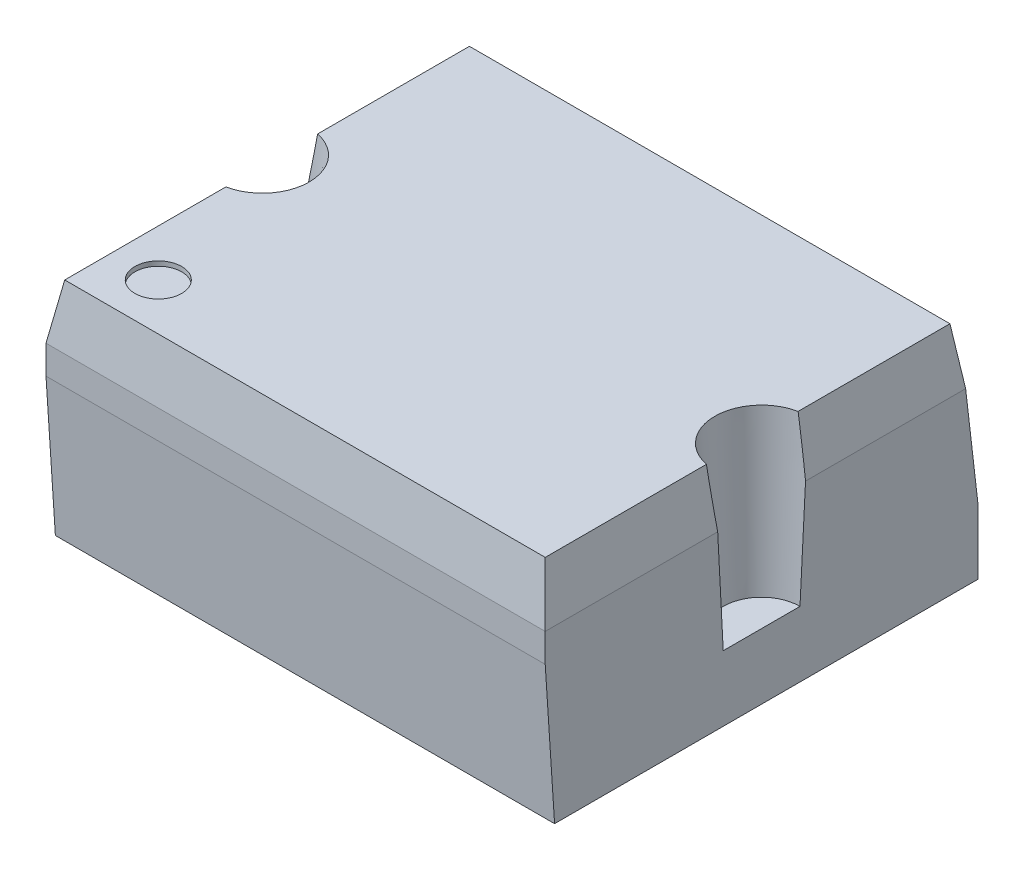
from build123d import *

# Parameters (mm, degrees)
SKETCH1_W           = 10.67
SKETCH1_H           = 9.25
BOSS_EXTRUDE1_DEPTH = 4.83
CUT_EXTRUDE1_DEPTH  = 11.67
CUT_EXTRUDE2_DEPTH  = 10.25
CUT_EXTRUDE3_DEPTH  = 11.67
CUT_EXTRUDE4_DEPTH  = 11.67
SKETCH7_R           = 1
CUT_EXTRUDE5_DEPTH  = 3.43
CUT_EXTRUDE5_TAPER  = 3
SKETCH8_R           = 0.5
CUT_EXTRUDE6_DEPTH  = 0.1


with BuildPart() as part:
    # Sketch1 → Boss-Extrude1 (new body)
    with BuildSketch(Plane(origin=(0, 0, 0), x_dir=(1, 0, 0), z_dir=(0, 1, 0))):
        Rectangle(SKETCH1_W, SKETCH1_H)
    extrude(amount=BOSS_EXTRUDE1_DEPTH)

    # Sketch3 → Cut-Extrude1 (cut, through all)
    with BuildSketch(Plane(origin=(5.335, 0, 0), x_dir=(0, 0, -1), z_dir=(1, 0, 0))):
        Polygon((4.625, 4.83), (4.225, 4.83), (4.625, 1.39), align=None)
    extrude(amount=-CUT_EXTRUDE1_DEPTH, mode=Mode.SUBTRACT)

    # Sketch4 → Cut-Extrude2 (cut, through all)
    with BuildSketch(Plane.XY.offset(4.625)):
        Polygon((5.335, 4.83), (5.135, 4.83), (5.335, 3.66), align=None)
    cut_extrude2 = extrude(amount=-CUT_EXTRUDE2_DEPTH, mode=Mode.SUBTRACT)

    # Mirror1: Cut-Extrude2 across plane
    add(cut_extrude2.mirror(Plane(origin=(0, 0, 0), x_dir=(0, 0, 1), z_dir=(1, 0, 0))), mode=Mode.SUBTRACT)

    # Sketch5 → Cut-Extrude3 (cut, through all)
    with BuildSketch(Plane.ZY.offset(5.335)):
        Polygon((4.425, 4.83), (4.625, 4.83), (4.625, 3.66), align=None)
    extrude(amount=-CUT_EXTRUDE3_DEPTH, mode=Mode.SUBTRACT)

    # Sketch6 → Cut-Extrude4 (cut, through all)
    with BuildSketch(Plane.ZY.offset(5.335)):
        Polygon((4.625, 0), (4.625, 3.05), (4.425, 0), align=None)
    extrude(amount=-CUT_EXTRUDE4_DEPTH, mode=Mode.SUBTRACT)

    # Sketch7 → Cut-Extrude5 (cut)
    with BuildSketch(Plane(origin=(0, 4.83, 0), x_dir=(1, 0, 0), z_dir=(0, 1, 0))):
        with Locations((-5.335, 0)):
            Circle(SKETCH7_R)
    cut_extrude5 = extrude(amount=-CUT_EXTRUDE5_DEPTH, taper=CUT_EXTRUDE5_TAPER, mode=Mode.SUBTRACT)

    # Mirror2: Cut-Extrude5 across plane
    add(cut_extrude5.mirror(Plane(origin=(0, 0, 0), x_dir=(0, 0, 1), z_dir=(1, 0, 0))), mode=Mode.SUBTRACT)

    # Sketch8 → Cut-Extrude6 (cut)
    with BuildSketch(Plane(origin=(0, 4.83, 0), x_dir=(1, 0, 0), z_dir=(0, 1, 0))):
        with Locations((-4.135, -3.425)):
            Circle(SKETCH8_R)
    extrude(amount=-CUT_EXTRUDE6_DEPTH, mode=Mode.SUBTRACT)


solid = part.part
